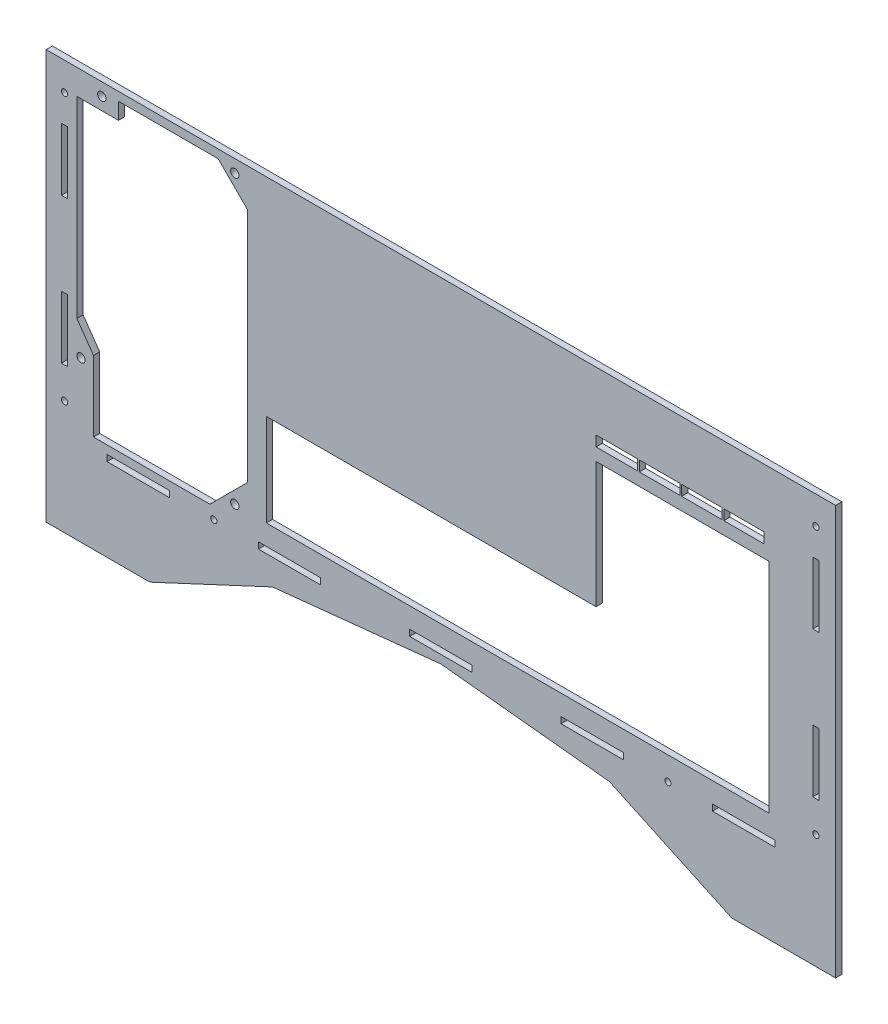
from build123d import *

# Parameters (mm, degrees)
SKETCH1_R           = 2
SKETCH1_R_2         = 1.5
SKETCH1_W           = 30
SKETCH1_H           = 3
SKETCH1_W_2         = 3
SKETCH1_H_2         = 30
SKETCH1_W_3         = 5
SKETCH1_H_3         = 19.9734
SKETCH1_H_4         = 19.45
BOSS_EXTRUDE1_DEPTH = 3


with BuildPart() as part:
    # Sketch1 → Boss-Extrude1 (new body)
    with BuildSketch(Plane(origin=(-12.611770594, -16.696126479, 0), x_dir=(0, -1, 0), z_dir=(0, 0, 1))):
        Polygon((-213.696126479, 12.611770594), (-213.696126479, 392.611770594), (-16.696126479, 392.611770594), (-16.696126479, 342.611770594), (-44.166313492, 283.701764437), (-52.593278212, 202.611770594), (-44.166313492, 121.521776752), (-16.696126479, 62.611770594), (-16.696126479, 12.611770594), align=None)
        with Locations((-207.593278212, 103.411770594)):
            Circle(SKETCH1_R, mode=Mode.SUBTRACT)
        with Locations((-69.593278212, 103.411770594)):
            Circle(SKETCH1_R, mode=Mode.SUBTRACT)
        with Locations((-93.593278212, 29.411770594)):
            Circle(SKETCH1_R, mode=Mode.SUBTRACT)
        with Locations((-207.593278212, 39.411770594)):
            Circle(SKETCH1_R, mode=Mode.SUBTRACT)
        with Locations((-200.179850585, 21.491770594)):
            Circle(SKETCH1_R_2, mode=Mode.SUBTRACT)
        with Locations((-58.093278212, 311.89748488)):
            Circle(SKETCH1_R_2, mode=Mode.SUBTRACT)
        with Locations((-200.196126479, 383.111770594)):
            Circle(SKETCH1_R_2, mode=Mode.SUBTRACT)
        with Locations((-71.696126479, 383.111770594)):
            Circle(SKETCH1_R_2, mode=Mode.SUBTRACT)
        with Locations((-58.093278212, 93.326056309)):
            Circle(SKETCH1_R_2, mode=Mode.SUBTRACT)
        with Locations((-71.679850585, 21.491770594)):
            Circle(SKETCH1_R_2, mode=Mode.SUBTRACT)
        Polygon((-209.593278212, 95.411770594), (-195.593278212, 109.411770594), (-81.593278212, 109.411770594), (-63.593278212, 91.411770594), (-63.593278212, 35.411770594), (-97.593278212, 35.411770594), (-109.018462266, 27.411770594), (-201.593276784, 27.411770594), (-201.593276784, 47.411770594), (-209.593278212, 47.411770594), align=None, mode=Mode.SUBTRACT)
        with Locations((-171.679850585, 21.491770594)):
            Rectangle(SKETCH1_W, SKETCH1_H, mode=Mode.SUBTRACT)
        with Locations((-101.679850585, 21.491770594)):
            Rectangle(SKETCH1_W, SKETCH1_H, mode=Mode.SUBTRACT)
        with Locations((-58.093278212, 56.89748488)):
            Rectangle(SKETCH1_W_2, SKETCH1_H_2, mode=Mode.SUBTRACT)
        with Locations((-58.093278212, 129.754627737)):
            Rectangle(SKETCH1_W_2, SKETCH1_H_2, mode=Mode.SUBTRACT)
        with Locations((-58.093278212, 202.611770594)):
            Rectangle(SKETCH1_W_2, SKETCH1_H_2, mode=Mode.SUBTRACT)
        with Locations((-58.093278212, 275.468913452)):
            Rectangle(SKETCH1_W_2, SKETCH1_H_2, mode=Mode.SUBTRACT)
        with Locations((-58.093278212, 348.326056309)):
            Rectangle(SKETCH1_W_2, SKETCH1_H_2, mode=Mode.SUBTRACT)
        with Locations((-101.696126479, 383.111770594)):
            Rectangle(SKETCH1_W, SKETCH1_H, mode=Mode.SUBTRACT)
        with Locations((-171.696126479, 383.111770594)):
            Rectangle(SKETCH1_W, SKETCH1_H, mode=Mode.SUBTRACT)
        Polygon((-69.353278212, 118.571770594), (-113.803278212, 118.571770594), (-113.803278212, 277.321770594), (-174.353278212, 277.321770594), (-174.353278212, 360.595170594), (-69.353278212, 360.595170594), align=None, mode=Mode.SUBTRACT)
        with Locations((-182.923278212, 287.308470594)):
            Rectangle(SKETCH1_W_3, SKETCH1_H_3, mode=Mode.SUBTRACT)
        with Locations((-182.923278212, 307.890170594)):
            Rectangle(SKETCH1_W_3, SKETCH1_H_4, mode=Mode.SUBTRACT)
        with Locations((-182.923278212, 328.210170594)):
            Rectangle(SKETCH1_W_3, SKETCH1_H_4, mode=Mode.SUBTRACT)
        with Locations((-182.923278212, 348.530170594)):
            Rectangle(SKETCH1_W_3, SKETCH1_H_4, mode=Mode.SUBTRACT)
    extrude(amount=BOSS_EXTRUDE1_DEPTH)


solid = part.part
